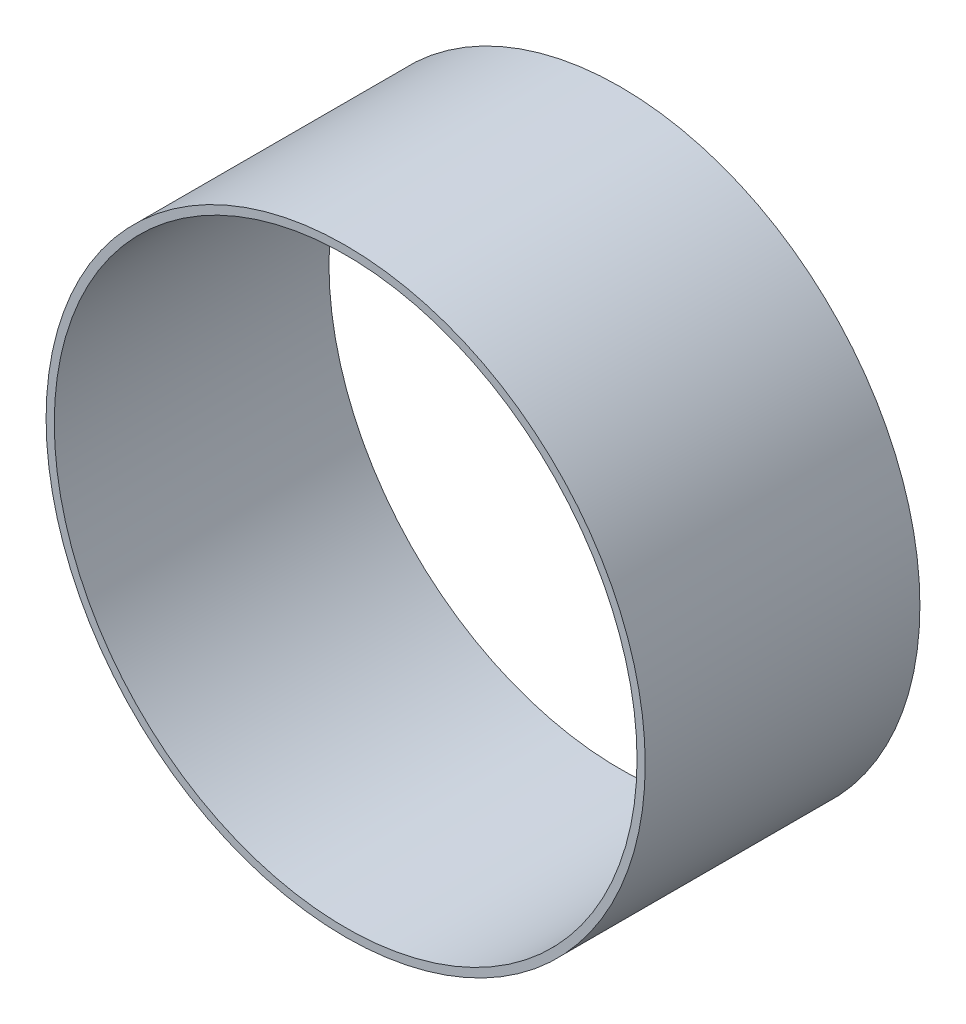
from build123d import *

# Parameters (mm, degrees)
SKETCH2_R           = 22.16
BOSS_EXTRUDE1_DEPTH = 20.32
SKETCH3_R           = 21.555
CUT_EXTRUDE1_DEPTH  = 20.32


with BuildPart() as part:
    # Sketch2 → Boss-Extrude1 (new body)
    with BuildSketch(Plane.XY):
        Circle(SKETCH2_R)
    extrude(amount=BOSS_EXTRUDE1_DEPTH)

    # Sketch3 → Cut-Extrude1 (cut)
    with BuildSketch(Plane.XY.offset(20.32)):
        Circle(SKETCH3_R)
    extrude(amount=-CUT_EXTRUDE1_DEPTH, mode=Mode.SUBTRACT)


solid = part.part
